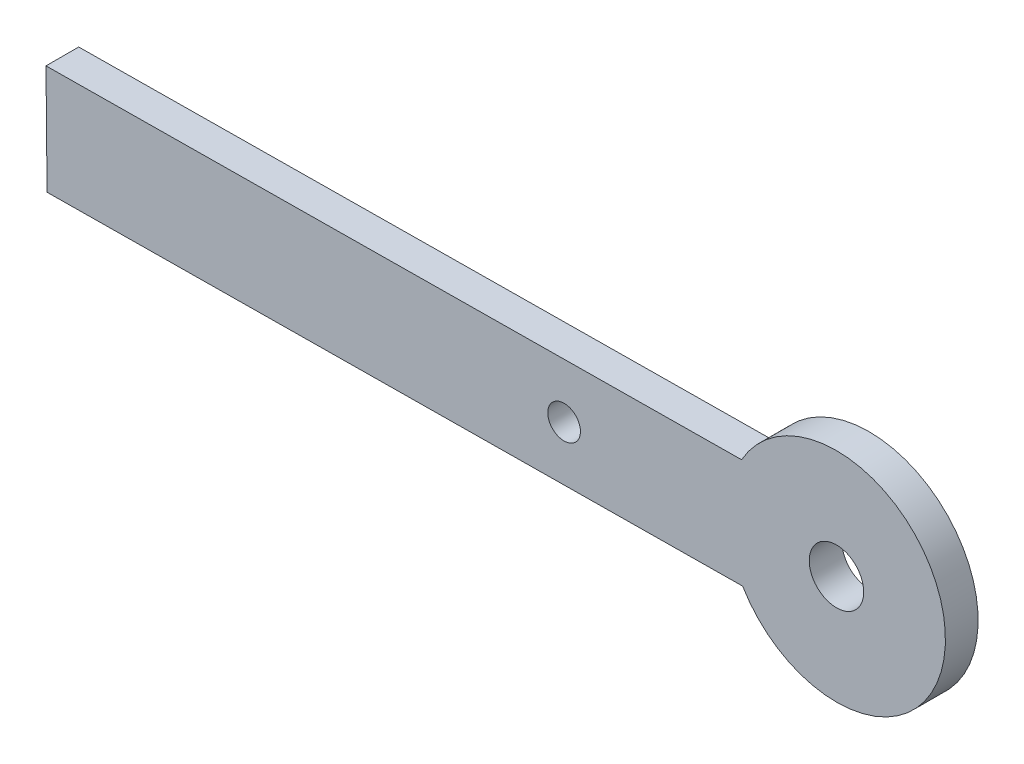
from build123d import *

# Parameters (mm, degrees)
SKETCH1_R           = 2.5
SKETCH1_R_2         = 1.500000002
BOSS_EXTRUDE1_DEPTH = 3


with BuildPart() as part:
    # Sketch1 → Boss-Extrude1 (new body)
    with BuildSketch(Plane.XY):
        with BuildLine():
            Line((-36.744474703, 67.343539136), (27.095525297, 67.958794059))
            ThreePointArc((27.095525297, 67.958794059), (45.803097829, 63.138855192), (27.191895339, 57.959258429))
            Line((27.191895339, 57.959258429), (-36.648104661, 57.344003506))
            Line((-36.648104661, 57.344003506), (-36.744474703, 67.343539136))
        make_face()
        with Locations((35.803562199, 63.04248515)):
            Circle(SKETCH1_R, mode=Mode.SUBTRACT)
        with Locations((10.804723125, 62.801560043)):
            Circle(SKETCH1_R_2, mode=Mode.SUBTRACT)
    extrude(amount=BOSS_EXTRUDE1_DEPTH)


solid = part.part
